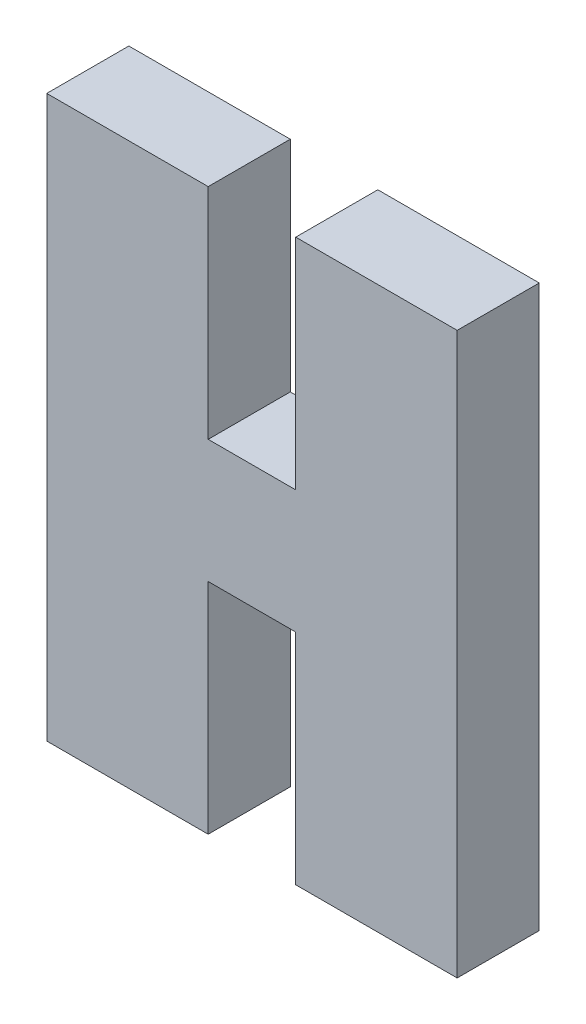
from build123d import *

# Parameters (mm, degrees)
CROQUIS1_W              = 5.9
CROQUIS1_H              = 8
CROQUIS1_W_2            = 15
CROQUIS1_H_2            = 4.5
SALIENTE_EXTRUIR1_DEPTH = 3


with BuildPart() as part:
    # Croquis1 → Saliente-Extruir1 (new body)
    with BuildSketch(Plane.XY):
        with Locations((-4.55, 6.25)):
            Rectangle(CROQUIS1_W, CROQUIS1_H)
        with Locations((4.55, 6.25)):
            Rectangle(CROQUIS1_W, CROQUIS1_H)
        Rectangle(CROQUIS1_W_2, CROQUIS1_H_2)
        with Locations((4.55, -6.25)):
            Rectangle(CROQUIS1_W, CROQUIS1_H)
        with Locations((-4.55, -6.25)):
            Rectangle(CROQUIS1_W, CROQUIS1_H)
    extrude(amount=SALIENTE_EXTRUIR1_DEPTH)


solid = part.part
